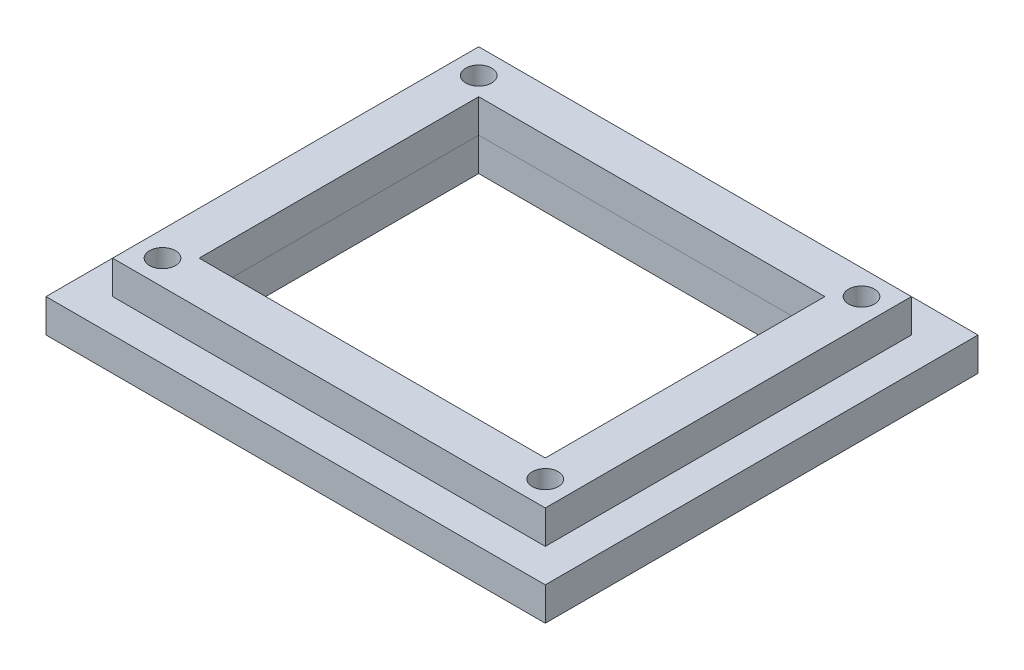
from build123d import *

# Parameters (mm, degrees)
SKETCH1_W           = 65
SKETCH1_H           = 55
SKETCH1_R           = 1.95
SKETCH1_W_2         = 52
SKETCH1_H_2         = 42
BOSS_EXTRUDE1_DEPTH = 5
SKETCH1_3_W         = 75
SKETCH1_3_H         = 65
SKETCH1_3_W_2       = 52
SKETCH1_3_H_2       = 42
BOSS_EXTRUDE2_DEPTH = 5
SKETCH2_R           = 1.95
CUT_EXTRUDE1_DEPTH  = 5


with BuildPart() as part:
    # Sketch1 → Boss-Extrude1 (new body)
    with BuildSketch(Plane(origin=(0, 0, 0), x_dir=(1, 0, 0), z_dir=(0, 1, 0))):
        Rectangle(SKETCH1_W, SKETCH1_H)
        with Locations((28.75, -23.75)):
            Circle(SKETCH1_R, mode=Mode.SUBTRACT)
        with Locations((28.75, 23.75)):
            Circle(SKETCH1_R, mode=Mode.SUBTRACT)
        with Locations((-28.75, 23.75)):
            Circle(SKETCH1_R, mode=Mode.SUBTRACT)
        with Locations((-28.75, -23.75)):
            Circle(SKETCH1_R, mode=Mode.SUBTRACT)
        Rectangle(SKETCH1_W_2, SKETCH1_H_2, mode=Mode.SUBTRACT)
    extrude(amount=BOSS_EXTRUDE1_DEPTH)


with BuildPart() as body_2:
    # Sketch1_3 → Boss-Extrude2 (new body)
    with BuildSketch(Plane(origin=(0, 0, 0), x_dir=(1, 0, 0), z_dir=(0, 1, 0))):
        Rectangle(SKETCH1_3_W, SKETCH1_3_H)
        Rectangle(SKETCH1_3_W_2, SKETCH1_3_H_2, mode=Mode.SUBTRACT)
    extrude(amount=-BOSS_EXTRUDE2_DEPTH)

    # Sketch2 → Cut-Extrude1 (cut)
    with BuildSketch(Plane.XZ.offset(5)):
        with Locations((-30, 25)):
            Circle(SKETCH2_R)
        with Locations((30, 25)):
            Circle(SKETCH2_R)
        with Locations((-30, -25)):
            Circle(SKETCH2_R)
        with Locations((30, -25)):
            Circle(SKETCH2_R)
    extrude(amount=-CUT_EXTRUDE1_DEPTH, mode=Mode.SUBTRACT)


solid = Compound([part.part, body_2.part])
